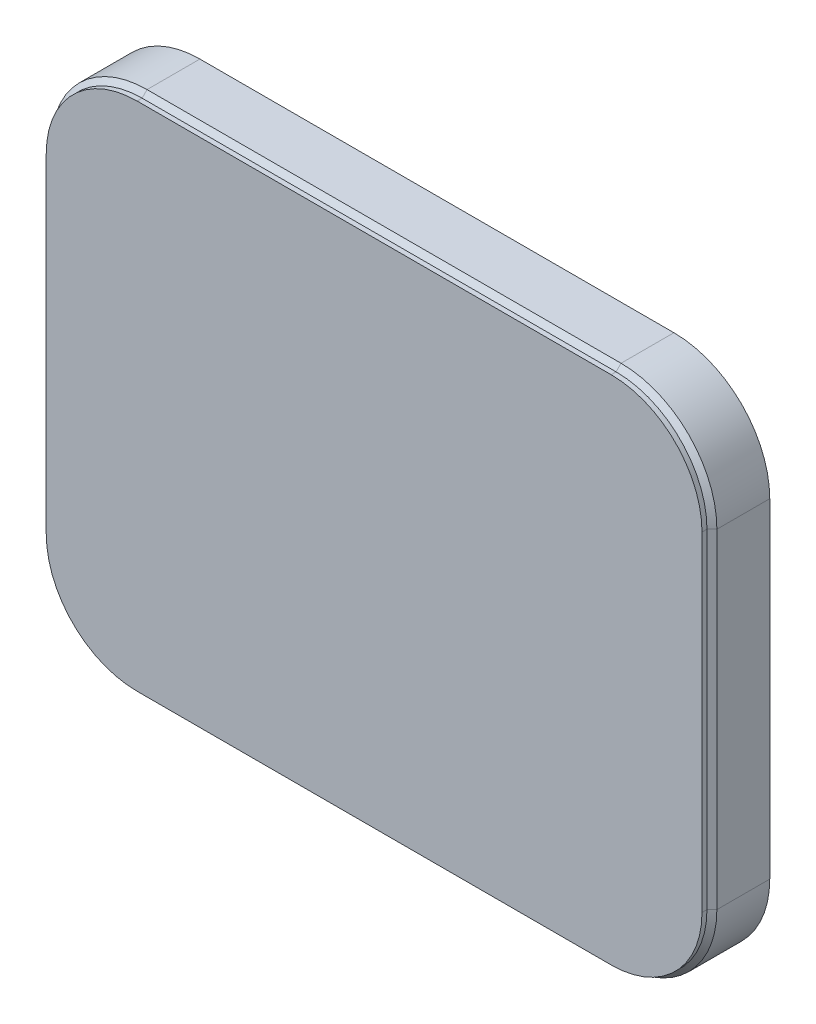
from build123d import *

# Parameters (mm, degrees)
BOSS_EXTRUDE1_DEPTH = 2.4
SKETCH2_R           = 32.5
BOSS_EXTRUDE2_DEPTH = 10
SKETCH3_R           = 29
BOSS_EXTRUDE3_DEPTH = 12
BOSS_EXTRUDE3_TAPER = 22.5


with BuildPart() as part:
    # Sweep2: sweep along a path in BasketRing
    with BuildLine(Plane.XY) as sweep2_path:
        Line((44, 0), (273.5, 0))
        ThreePointArc((273.5, 0), (304.612698372, 12.887301628), (317.5, 44))
        Line((317.5, 44), (317.5, 203.5))
        ThreePointArc((317.5, 203.5), (304.612698372, 234.612698372), (273.5, 247.5))
        Line((273.5, 247.5), (44, 247.5))
        ThreePointArc((44, 247.5), (12.887301628, 234.612698372), (0, 203.5))
        Line((0, 203.5), (0, 44))
        ThreePointArc((0, 44), (12.887301628, 12.887301628), (44, 0))
    # ShapeOf Edge → Sweep2 (sweep)
    with BuildSketch(Plane(origin=(44, 0, 0), x_dir=(0, 0, -1), z_dir=(1, 0, 0))):
        Polygon((0, 0), (2.4, 0), (4.8, -2.4), (30.4, -2.4), (30.4, 0), (5.79411255, 0), (2.4, 3.39411255), (2.4, 7), (0, 7), align=None)
    sweep(path=sweep2_path.line)

    # Sketch1 → Boss-Extrude1 (add)
    with BuildSketch(Plane.XY):
        with BuildLine():
            Line((44, 240.5), (273.5, 240.5))
            ThreePointArc((273.5, 240.5), (299.662950904, 229.662950904), (310.5, 203.5))
            Line((310.5, 203.5), (310.5, 44))
            ThreePointArc((310.5, 44), (299.662950904, 17.837049096), (273.5, 7))
            Line((273.5, 7), (44, 7))
            ThreePointArc((44, 7), (17.837049096, 17.837049096), (7, 44))
            Line((7, 44), (7, 203.5))
            ThreePointArc((7, 203.5), (17.837049096, 229.662950904), (44, 240.5))
        make_face()
    extrude(amount=-BOSS_EXTRUDE1_DEPTH)

    # Sketch2 → Boss-Extrude2 (add)
    with BuildSketch(Plane(origin=(0, 0, -2.4), x_dir=(-1, 0, 0), z_dir=(0, 0, -1))):
        with Locations((-158.75, 123.75)):
            Circle(SKETCH2_R)
    extrude(amount=BOSS_EXTRUDE2_DEPTH)

    # Sketch3 → Boss-Extrude3 (add)
    with BuildSketch(Plane(origin=(0, 0, -12.4), x_dir=(-1, 0, 0), z_dir=(0, 0, -1))):
        with Locations((-158.75, 123.75)):
            Circle(SKETCH3_R)
    extrude(amount=BOSS_EXTRUDE3_DEPTH, taper=BOSS_EXTRUDE3_TAPER)


solid = part.part
